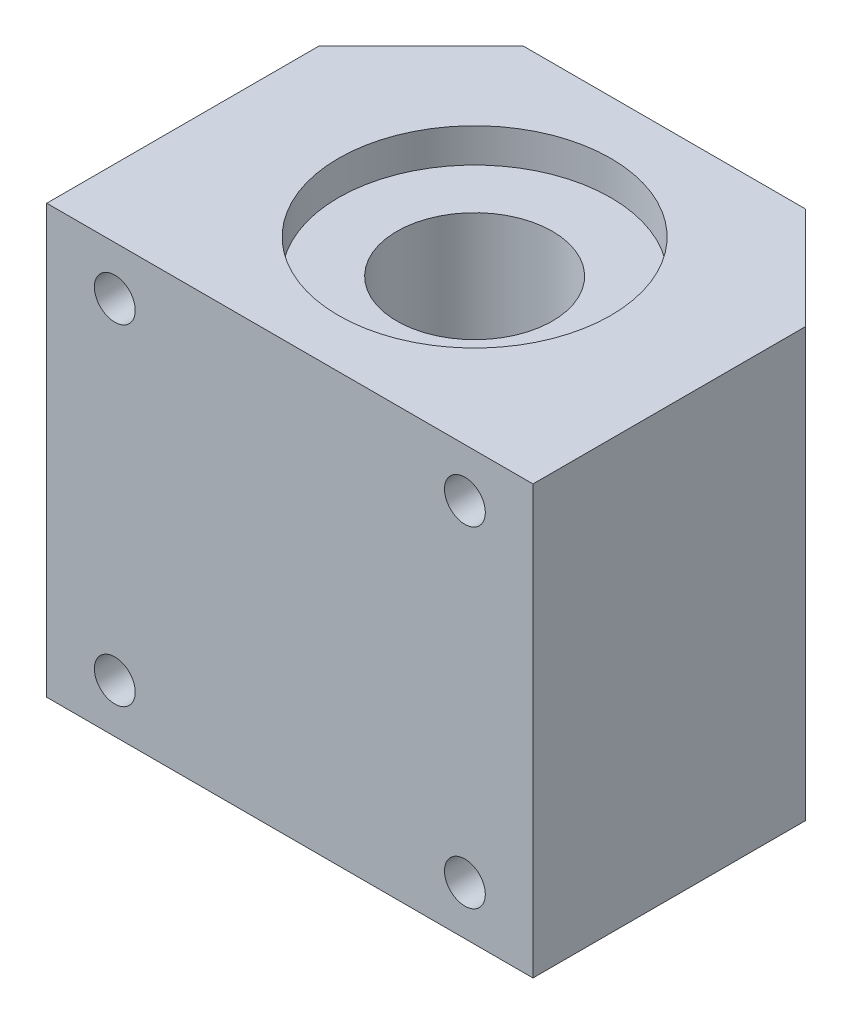
from build123d import *

# Parameters (mm, degrees)
SKETCH1_W           = 50
SKETCH1_H           = 44
BOSS_EXTRUDE1_DEPTH = 38.5
M5_TAPPED_HOLE1_D   = 4.2
SKETCH6_R           = 14
CUT_EXTRUDE1_DEPTH  = 45
SKETCH8_R           = 14
SKETCH8_R_2         = 8
BOSS_EXTRUDE2_DEPTH = 18.5


with BuildPart() as part:
    # Sketch1 → Boss-Extrude1 (new body)
    with BuildSketch(Plane.XY):
        Rectangle(SKETCH1_W, SKETCH1_H)
    extrude(amount=BOSS_EXTRUDE1_DEPTH)

    # M5 Tapped Hole1 (through all)
    with Locations(Plane.XY.offset(38.5)):
        with Locations((-18, 17), (18, 17), (18, -17), (-18, -17)):
            Hole(M5_TAPPED_HOLE1_D / 2)

    # Sketch6 → Cut-Extrude1 (cut, through all)
    with BuildSketch(Plane(origin=(0, 22, 0), x_dir=(1, 0, 0), z_dir=(0, 1, 0))):
        with Locations((0, -19.5)):
            Circle(SKETCH6_R)
        Polygon((-25, -10.5), (-14.5, 0), (-25, 0), align=None)
        Polygon((25, -10.5), (14.5, 0), (25, 0), align=None)
    extrude(amount=-CUT_EXTRUDE1_DEPTH, mode=Mode.SUBTRACT)

    # Sketch8 → Boss-Extrude2 (add, symmetric)
    with BuildSketch(Plane(origin=(0, 0, 0), x_dir=(-1, 0, 0), z_dir=(0, -1, 0))):
        with Locations((0, -19.5)):
            Circle(SKETCH8_R)
        with Locations((0, -19.5)):
            Circle(SKETCH8_R_2, mode=Mode.SUBTRACT)
    extrude(amount=BOSS_EXTRUDE2_DEPTH, both=True)


solid = part.part
